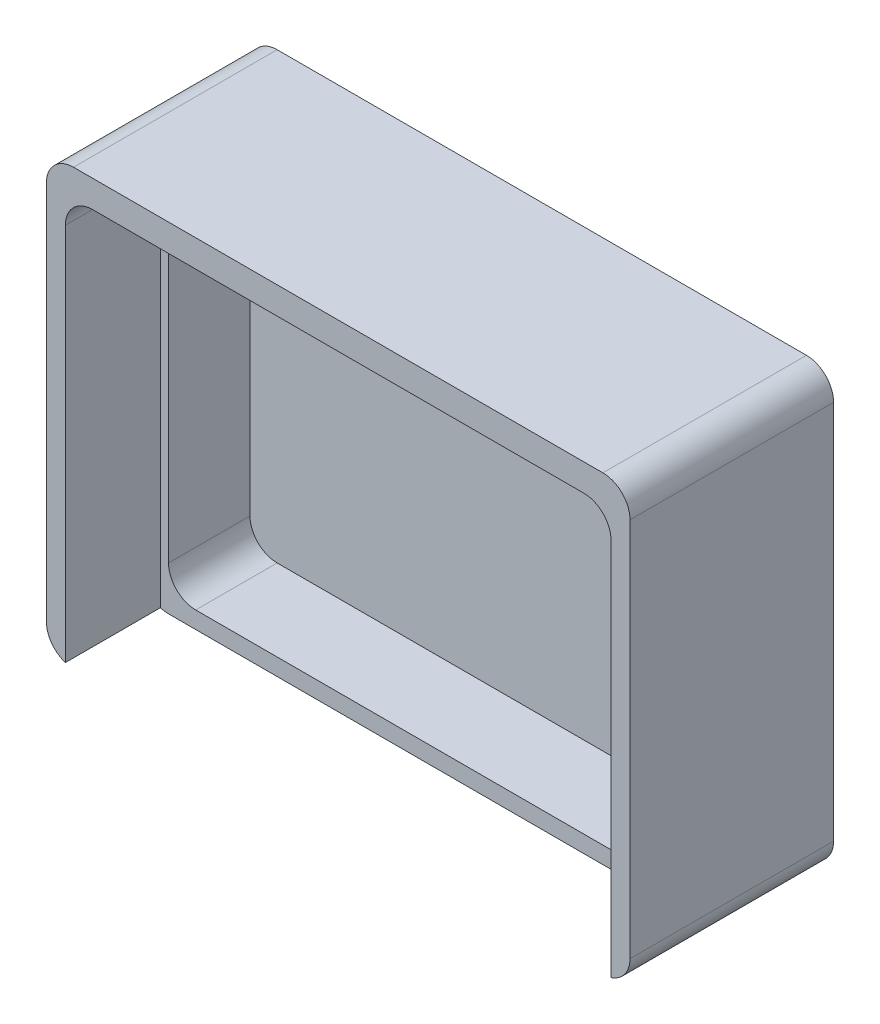
from build123d import *

# Parameters (mm, degrees)
SKETCH1_W           = 43
SKETCH1_H           = 32
BOSS_EXTRUDE1_DEPTH = 15
SKETCH2_W           = 40.2
SKETCH2_H           = 30
CUT_EXTRUDE1_DEPTH  = 7
SKETCH3_W           = 39
SKETCH3_H           = 28
CUT_EXTRUDE2_DEPTH  = 6
FILLET2_R           = 2
FILLET4_R           = 2


with BuildPart() as part:
    # Sketch1 → Boss-Extrude1 (new body)
    with BuildSketch(Plane.XY):
        with Locations((0, -0.875)):
            Rectangle(SKETCH1_W, SKETCH1_H)
    extrude(amount=BOSS_EXTRUDE1_DEPTH)

    # Sketch2 → Cut-Extrude1 (cut)
    with BuildSketch(Plane.XY.offset(15)):
        with Locations((0, -1.875)):
            Rectangle(SKETCH2_W, SKETCH2_H)
    extrude(amount=-CUT_EXTRUDE1_DEPTH, mode=Mode.SUBTRACT)

    # Sketch3 → Cut-Extrude2 (cut)
    with BuildSketch(Plane.XY.offset(8)):
        with Locations((0, -1.625)):
            Rectangle(SKETCH3_W, SKETCH3_H)
    extrude(amount=-CUT_EXTRUDE2_DEPTH, mode=Mode.SUBTRACT)

    # Fillet2
    fillet2_edges = [part.edges().sort_by_distance(p)[0] for p in [
        (20.1, 13.125, 11.5),
        (-20.1, 13.125, 11.5),
        (19.5, 12.375, 5),
        (19.5, -15.625, 5),
        (-19.5, -15.625, 5),
        (-19.5, 12.375, 5),
    ]]
    fillet(fillet2_edges, radius=FILLET2_R)

    # Fillet4
    fillet4_edges = [part.edges().sort_by_distance(p)[0] for p in [
        (-21.5, -16.875, 7.5),
        (21.5, -16.875, 7.5),
        (21.5, 15.125, 7.5),
        (-21.5, 15.125, 7.5),
    ]]
    fillet(fillet4_edges, radius=FILLET4_R)


solid = part.part
